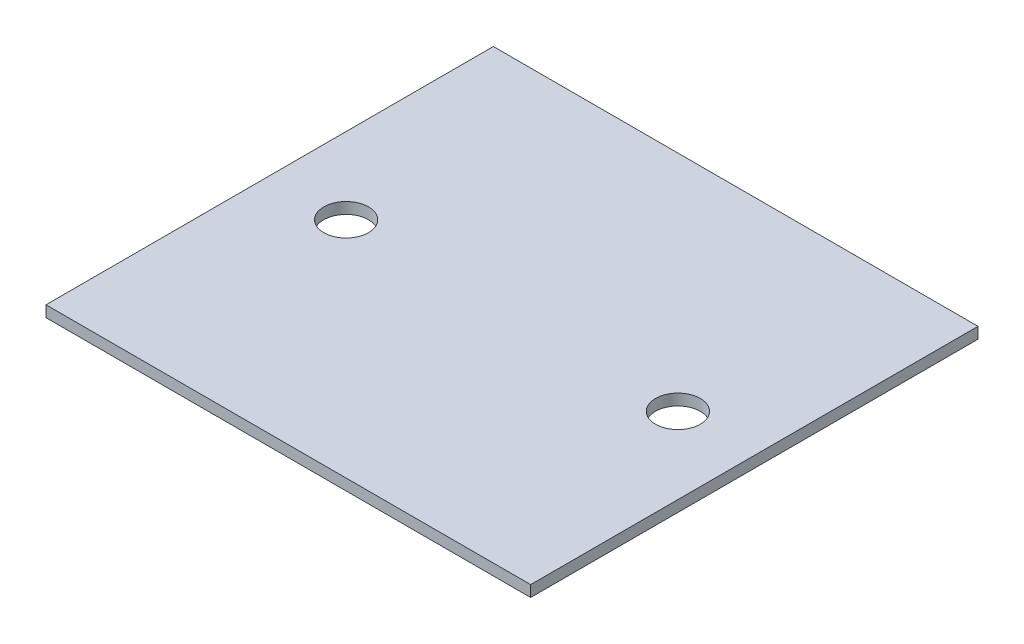
from build123d import *

# Parameters (mm, degrees)
SKETCH1_W           = 130
SKETCH1_H           = 120
BOSS_EXTRUDE1_DEPTH = 3
CUT_EXTRUDE1_START  = -4
SKETCH2_R           = 6
CUT_EXTRUDE1_DEPTH  = 5


with BuildPart() as part:
    # Sketch1 → Boss-Extrude1 (new body)
    with BuildSketch(Plane(origin=(0, 0, 0), x_dir=(1, 0, 0), z_dir=(0, 1, 0))):
        Rectangle(SKETCH1_W, SKETCH1_H)
    extrude(amount=BOSS_EXTRUDE1_DEPTH)

    # Sketch2 → Cut-Extrude1 (cut)
    with BuildSketch(Plane(origin=(0, 3, 0), x_dir=(1, 0, 0), z_dir=(0, 1, 0)).offset(CUT_EXTRUDE1_START)):
        with Locations((44.5, 0)):
            Circle(SKETCH2_R)
    cut_extrude1 = extrude(amount=CUT_EXTRUDE1_DEPTH, mode=Mode.SUBTRACT)

    # Mirror1: Cut-Extrude1 across plane
    add(cut_extrude1.mirror(Plane(origin=(0, 0, 0), x_dir=(0, 0, 1), z_dir=(1, 0, 0))), mode=Mode.SUBTRACT)


solid = part.part
